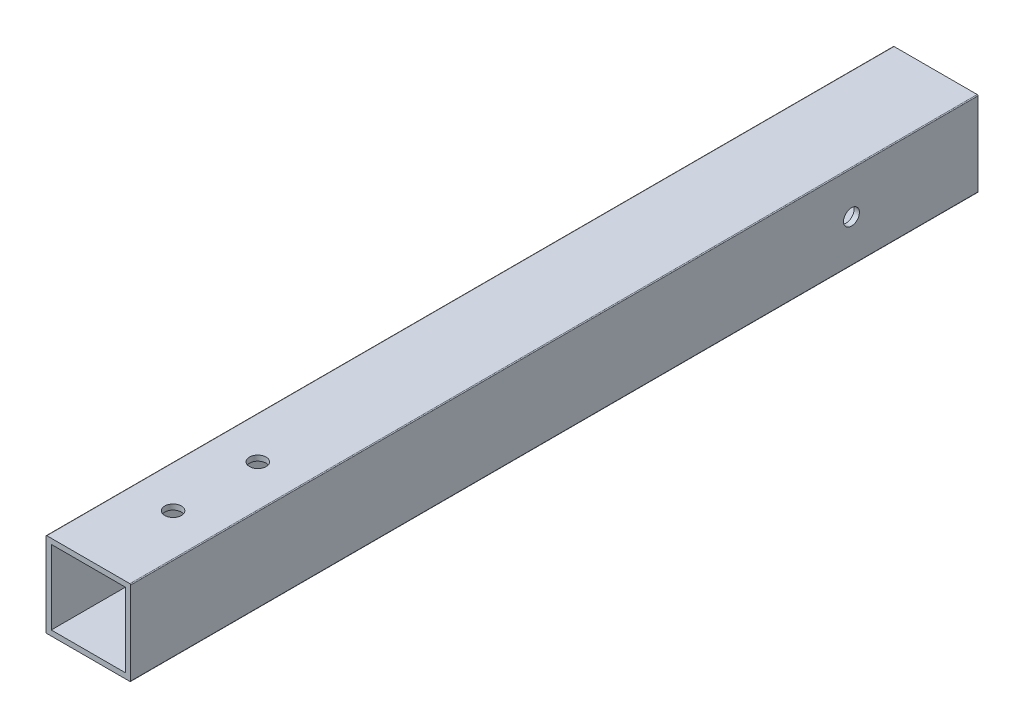
from build123d import *

# Parameters (mm, degrees)
SKETCH1_W           = 22.225
SKETCH1_H           = 22.225
BOSS_EXTRUDE1_DEPTH = 254
SKETCH4_R           = 2.38125
CUT_EXTRUDE2_DEPTH  = 257.375106351
SKETCH6_R           = 2.4892
CUT_EXTRUDE3_DEPTH  = 25.4


with BuildPart() as part:
    # Sketch1 → Boss-Extrude1 (new body)
    with BuildSketch(Plane(origin=(0, 0, 0), x_dir=(-1, 0, 0), z_dir=(0, 0, -1))):
        with BuildLine():
            Line((1.5875, -1.3335), (1.5875, 23.5585))
            ThreePointArc((1.5875, 23.5585), (1.513105122, 23.738105122), (1.3335, 23.8125))
            Line((1.3335, 23.8125), (-23.5585, 23.8125))
            ThreePointArc((-23.5585, 23.8125), (-23.738105122, 23.738105122), (-23.8125, 23.5585))
            Line((-23.8125, 23.5585), (-23.8125, -1.3335))
            ThreePointArc((-23.8125, -1.3335), (-23.738105122, -1.513105122), (-23.5585, -1.5875))
            Line((-23.5585, -1.5875), (1.3335, -1.5875))
            ThreePointArc((1.3335, -1.5875), (1.513105122, -1.513105122), (1.5875, -1.3335))
        make_face()
        with Locations((-11.1125, 11.1125)):
            Rectangle(SKETCH1_W, SKETCH1_H, mode=Mode.SUBTRACT)
    extrude(amount=-BOSS_EXTRUDE1_DEPTH)

    # Sketch4 → Cut-Extrude2 (cut, through all)
    with BuildSketch(Plane(origin=(23.8125, 0, 0), x_dir=(0, 0, -1), z_dir=(1, 0, 0))):
        with Locations((-37.933268304, 11.1125)):
            Circle(SKETCH4_R)
    extrude(amount=-CUT_EXTRUDE2_DEPTH, mode=Mode.SUBTRACT)

    # Sketch6 → Cut-Extrude3 (cut)
    with BuildSketch(Plane(origin=(0, 23.8125, 0), x_dir=(1, 0, 0), z_dir=(0, 1, 0))):
        with Locations((11.1125, -203.2)):
            Circle(SKETCH6_R)
        with Locations((11.1125, -228.6)):
            Circle(SKETCH6_R)
    extrude(amount=-CUT_EXTRUDE3_DEPTH, mode=Mode.SUBTRACT)


solid = part.part
